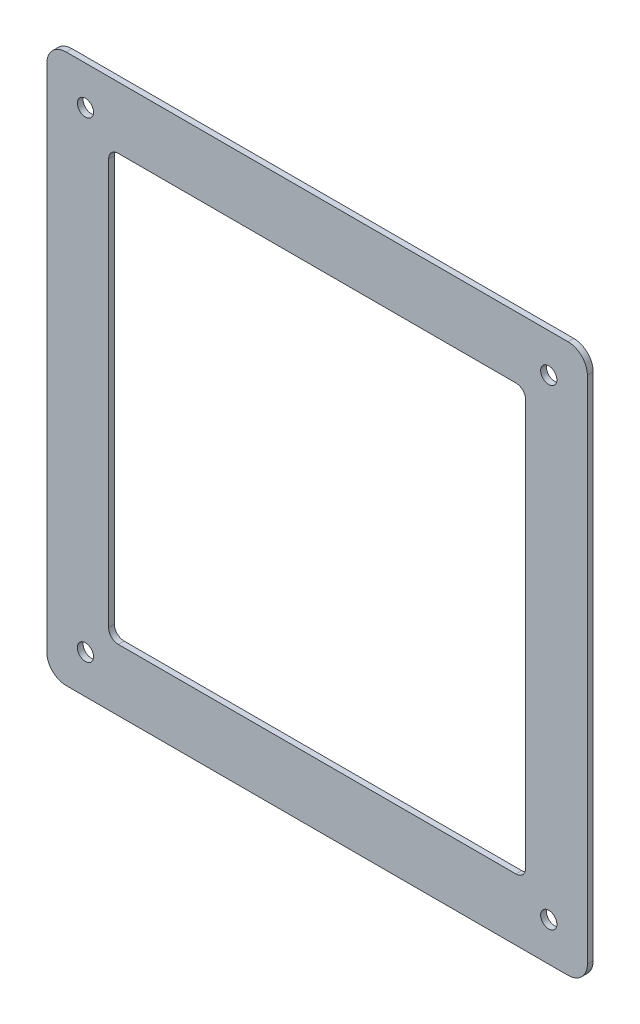
from build123d import *

# Parameters (mm, degrees)
SKETCH_1_W              = 280
SKETCH_1_H              = 284.25
SKETCH_1_W_2            = 216
SKETCH_1_H_2            = 220.25
EXTRUDE_1_DEPTH         = 3
FILLET_1_R              = 10
FILLET_2_R              = 5
HOLE_WIZARD_8_4_8_4_1_D = 8.4


with BuildPart() as part:
    # 草图1 → 凸台-拉伸1 (new body)
    with BuildSketch(Plane.XY):
        Rectangle(SKETCH_1_W, SKETCH_1_H)
        Rectangle(SKETCH_1_W_2, SKETCH_1_H_2, mode=Mode.SUBTRACT)
    extrude(amount=EXTRUDE_1_DEPTH)

    # 圆角1
    fillet_1_edges = [part.edges().sort_by_distance(p)[0] for p in [
        (140, -142.125, 1.5),
        (-140, -142.125, 1.5),
        (-140, 142.125, 1.5),
        (140, 142.125, 1.5),
    ]]
    fillet(fillet_1_edges, radius=FILLET_1_R)

    # 圆角2
    fillet_2_edges = [part.edges().sort_by_distance(p)[0] for p in [
        (108, -110.125, 1.5),
        (108, 110.125, 1.5),
        (-108, 110.125, 1.5),
        (-108, -110.125, 1.5),
    ]]
    fillet(fillet_2_edges, radius=FILLET_2_R)

    # Ø8.4 (8.4) 直径孔1 (through all)
    with Locations(Plane.XY.offset(3)):
        with Locations((120, -122.125), (-120, 122.125), (-120, -122.125), (120, 122.125)):
            Hole(HOLE_WIZARD_8_4_8_4_1_D / 2)


solid = part.part
